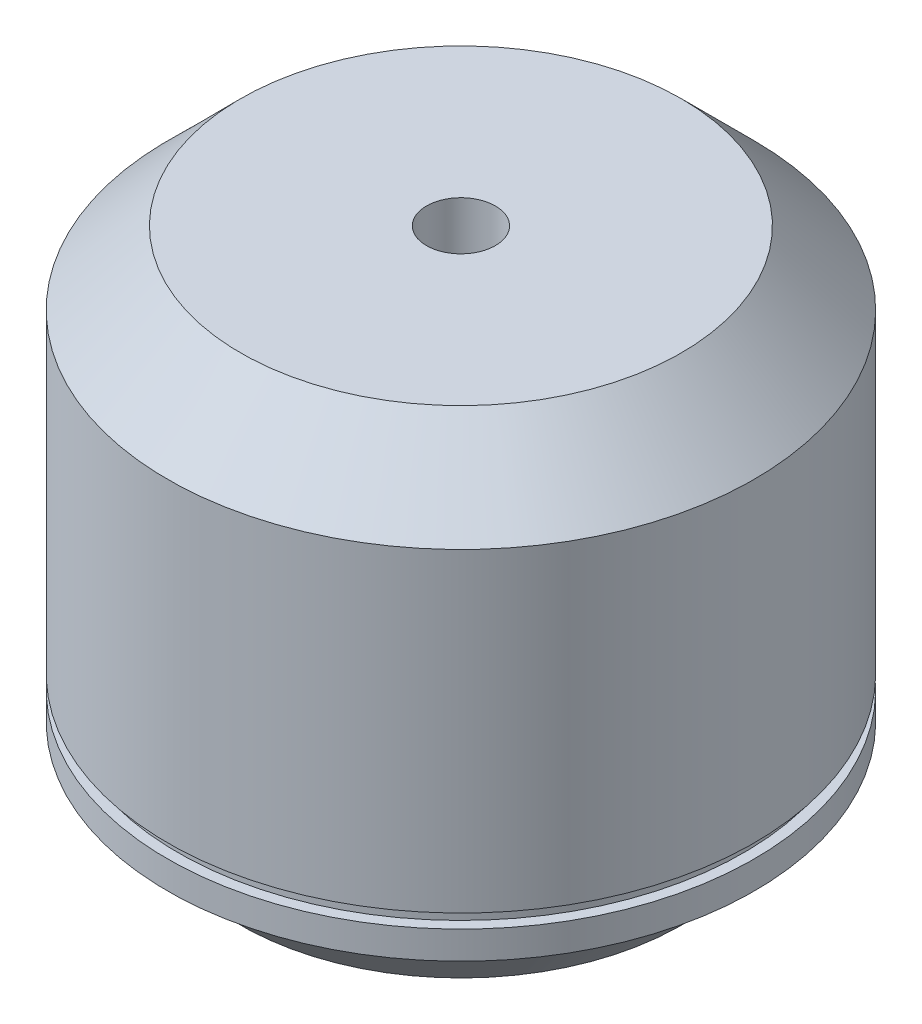
from build123d import *

# Parameters (mm, degrees)
SKETCH2_R          = 1.5
CUT_EXTRUDE1_DEPTH = 5


with BuildPart() as part:
    # Sketch1 → Revolve1 (revolve)
    with BuildSketch(Plane.XY):
        Polygon((8, 0), (16, 0), (20.8, 4.8), (21.3, 4.8), (21.3, 6.821980551), (20.529759762, 6.821980551), (20.529759762, 7.830949193), (21.3, 7.830949193), (21.3, 30.7), (16, 36), (2.5, 36), (2.5, 1), (8, 1), align=None)
    revolve(axis=Axis((0, 0, 0), (0, 1, 0)))

    # Sketch2 → Cut-Extrude1 (cut)
    with BuildSketch(Plane.XZ):
        with Locations((-8.838834765, 8.838834765)):
            Circle(SKETCH2_R)
        with Locations((8.838834765, 8.838834765)):
            Circle(SKETCH2_R)
        with Locations((8.838834765, -8.838834765)):
            Circle(SKETCH2_R)
        with Locations((-8.838834765, -8.838834765)):
            Circle(SKETCH2_R)
    extrude(amount=-CUT_EXTRUDE1_DEPTH, mode=Mode.SUBTRACT)


solid = part.part
